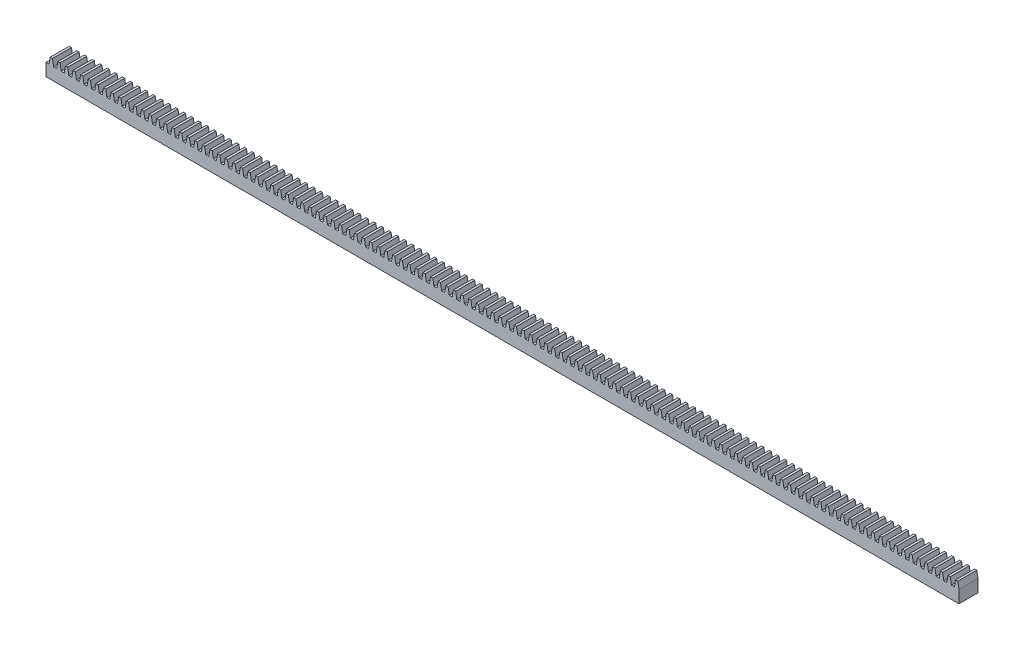
from build123d import *

# Parameters (mm, degrees)
SKETCH1_W           = 6.35
SKETCH1_H           = 6.35
BOSS_EXTRUDE1_DEPTH = 304.8
CUT_EXTRUDE1_DEPTH  = 304.8
SKETCH3_R           = 1.3462
CUT_EXTRUDE2_DEPTH  = 4.572


with BuildPart() as part:
    # Sketch1 → Boss-Extrude1 (new body)
    with BuildSketch(Plane(origin=(0, 0, 0), x_dir=(0, 0, -1), z_dir=(1, 0, 0))):
        with Locations((3.175, 3.175)):
            Rectangle(SKETCH1_W, SKETCH1_H)
    extrude(amount=-BOSS_EXTRUDE1_DEPTH)

    # Sketch2 → Cut-Extrude1 (cut)
    with BuildSketch(Plane.XY):
        Polygon((-5.08, 4.1402), (-5.469647362, 6.35), (-3.674352638, 6.35), (-4.064, 4.1402), align=None)
        Polygon((-1.524, 4.1402), (-1.134352638, 6.35), (-2.929647362, 6.35), (-2.54, 4.1402), align=None)
        Polygon((-7.62, 4.1402), (-8.009647362, 6.35), (-6.214352638, 6.35), (-6.604, 4.1402), align=None)
        Polygon((-10.16, 4.1402), (-10.549647362, 6.35), (-8.754352638, 6.35), (-9.144, 4.1402), align=None)
        Polygon((-12.7, 4.1402), (-13.089647362, 6.35), (-11.294352638, 6.35), (-11.684, 4.1402), align=None)
        Polygon((-15.24, 4.1402), (-15.629647362, 6.35), (-13.834352638, 6.35), (-14.224, 4.1402), align=None)
        Polygon((-17.78, 4.1402), (-18.169647362, 6.35), (-16.374352638, 6.35), (-16.764, 4.1402), align=None)
        Polygon((-20.32, 4.1402), (-20.709647362, 6.35), (-18.914352638, 6.35), (-19.304, 4.1402), align=None)
        Polygon((-22.86, 4.1402), (-23.249647362, 6.35), (-21.454352638, 6.35), (-21.844, 4.1402), align=None)
        Polygon((-25.4, 4.1402), (-25.789647362, 6.35), (-23.994352638, 6.35), (-24.384, 4.1402), align=None)
        Polygon((-27.94, 4.1402), (-28.329647362, 6.35), (-26.534352638, 6.35), (-26.924, 4.1402), align=None)
        Polygon((-30.48, 4.1402), (-30.869647362, 6.35), (-29.074352638, 6.35), (-29.464, 4.1402), align=None)
        Polygon((-33.02, 4.1402), (-33.409647362, 6.35), (-31.614352638, 6.35), (-32.004, 4.1402), align=None)
        Polygon((-35.56, 4.1402), (-35.949647362, 6.35), (-34.154352638, 6.35), (-34.544, 4.1402), align=None)
        Polygon((-38.1, 4.1402), (-38.489647362, 6.35), (-36.694352638, 6.35), (-37.084, 4.1402), align=None)
        Polygon((-40.64, 4.1402), (-41.029647362, 6.35), (-39.234352638, 6.35), (-39.624, 4.1402), align=None)
        Polygon((-43.18, 4.1402), (-43.569647362, 6.35), (-41.774352638, 6.35), (-42.164, 4.1402), align=None)
        Polygon((-45.72, 4.1402), (-46.109647362, 6.35), (-44.314352638, 6.35), (-44.704, 4.1402), align=None)
        Polygon((-48.26, 4.1402), (-48.649647362, 6.35), (-46.854352638, 6.35), (-47.244, 4.1402), align=None)
        Polygon((-50.8, 4.1402), (-51.189647362, 6.35), (-49.394352638, 6.35), (-49.784, 4.1402), align=None)
        Polygon((-53.34, 4.1402), (-53.729647362, 6.35), (-51.934352638, 6.35), (-52.324, 4.1402), align=None)
        Polygon((-55.88, 4.1402), (-56.269647362, 6.35), (-54.474352638, 6.35), (-54.864, 4.1402), align=None)
        Polygon((-58.42, 4.1402), (-58.809647362, 6.35), (-57.014352638, 6.35), (-57.404, 4.1402), align=None)
        Polygon((-60.96, 4.1402), (-61.349647362, 6.35), (-59.554352638, 6.35), (-59.944, 4.1402), align=None)
        Polygon((-63.5, 4.1402), (-63.889647362, 6.35), (-62.094352638, 6.35), (-62.484, 4.1402), align=None)
        Polygon((-66.04, 4.1402), (-66.429647362, 6.35), (-64.634352638, 6.35), (-65.024, 4.1402), align=None)
        Polygon((-68.58, 4.1402), (-68.969647362, 6.35), (-67.174352638, 6.35), (-67.564, 4.1402), align=None)
        Polygon((-71.12, 4.1402), (-71.509647362, 6.35), (-69.714352638, 6.35), (-70.104, 4.1402), align=None)
        Polygon((-73.66, 4.1402), (-74.049647362, 6.35), (-72.254352638, 6.35), (-72.644, 4.1402), align=None)
        Polygon((-76.2, 4.1402), (-76.589647362, 6.35), (-74.794352638, 6.35), (-75.184, 4.1402), align=None)
        Polygon((-78.74, 4.1402), (-79.129647362, 6.35), (-77.334352638, 6.35), (-77.724, 4.1402), align=None)
        Polygon((-81.28, 4.1402), (-81.669647362, 6.35), (-79.874352638, 6.35), (-80.264, 4.1402), align=None)
        Polygon((-83.82, 4.1402), (-84.209647362, 6.35), (-82.414352638, 6.35), (-82.804, 4.1402), align=None)
        Polygon((-86.36, 4.1402), (-86.749647362, 6.35), (-84.954352638, 6.35), (-85.344, 4.1402), align=None)
        Polygon((-88.9, 4.1402), (-89.289647362, 6.35), (-87.494352638, 6.35), (-87.884, 4.1402), align=None)
        Polygon((-91.44, 4.1402), (-91.829647362, 6.35), (-90.034352638, 6.35), (-90.424, 4.1402), align=None)
        Polygon((-93.98, 4.1402), (-94.369647362, 6.35), (-92.574352638, 6.35), (-92.964, 4.1402), align=None)
        Polygon((-96.52, 4.1402), (-96.909647362, 6.35), (-95.114352638, 6.35), (-95.504, 4.1402), align=None)
        Polygon((-99.06, 4.1402), (-99.449647362, 6.35), (-97.654352638, 6.35), (-98.044, 4.1402), align=None)
        Polygon((-101.6, 4.1402), (-101.989647362, 6.35), (-100.194352638, 6.35), (-100.584, 4.1402), align=None)
        Polygon((-104.14, 4.1402), (-104.529647362, 6.35), (-102.734352638, 6.35), (-103.124, 4.1402), align=None)
        Polygon((-106.68, 4.1402), (-107.069647362, 6.35), (-105.274352638, 6.35), (-105.664, 4.1402), align=None)
        Polygon((-109.22, 4.1402), (-109.609647362, 6.35), (-107.814352638, 6.35), (-108.204, 4.1402), align=None)
        Polygon((-111.76, 4.1402), (-112.149647362, 6.35), (-110.354352638, 6.35), (-110.744, 4.1402), align=None)
        Polygon((-114.3, 4.1402), (-114.689647362, 6.35), (-112.894352638, 6.35), (-113.284, 4.1402), align=None)
        Polygon((-116.84, 4.1402), (-117.229647362, 6.35), (-115.434352638, 6.35), (-115.824, 4.1402), align=None)
        Polygon((-119.38, 4.1402), (-119.769647362, 6.35), (-117.974352638, 6.35), (-118.364, 4.1402), align=None)
        Polygon((-121.92, 4.1402), (-122.309647362, 6.35), (-120.514352638, 6.35), (-120.904, 4.1402), align=None)
        Polygon((-124.46, 4.1402), (-124.849647362, 6.35), (-123.054352638, 6.35), (-123.444, 4.1402), align=None)
        Polygon((-127, 4.1402), (-127.389647362, 6.35), (-125.594352638, 6.35), (-125.984, 4.1402), align=None)
        Polygon((-129.54, 4.1402), (-129.929647362, 6.35), (-128.134352638, 6.35), (-128.524, 4.1402), align=None)
        Polygon((-132.08, 4.1402), (-132.469647362, 6.35), (-130.674352638, 6.35), (-131.064, 4.1402), align=None)
        Polygon((-134.62, 4.1402), (-135.009647362, 6.35), (-133.214352638, 6.35), (-133.604, 4.1402), align=None)
        Polygon((-137.16, 4.1402), (-137.549647362, 6.35), (-135.754352638, 6.35), (-136.144, 4.1402), align=None)
        Polygon((-139.7, 4.1402), (-140.089647362, 6.35), (-138.294352638, 6.35), (-138.684, 4.1402), align=None)
        Polygon((-142.24, 4.1402), (-142.629647362, 6.35), (-140.834352638, 6.35), (-141.224, 4.1402), align=None)
        Polygon((-144.78, 4.1402), (-145.169647362, 6.35), (-143.374352638, 6.35), (-143.764, 4.1402), align=None)
        Polygon((-147.32, 4.1402), (-147.709647362, 6.35), (-145.914352638, 6.35), (-146.304, 4.1402), align=None)
        Polygon((-149.86, 4.1402), (-150.249647362, 6.35), (-148.454352638, 6.35), (-148.844, 4.1402), align=None)
        Polygon((-152.4, 4.1402), (-152.789647362, 6.35), (-150.994352638, 6.35), (-151.384, 4.1402), align=None)
        Polygon((-154.94, 4.1402), (-155.329647362, 6.35), (-153.534352638, 6.35), (-153.924, 4.1402), align=None)
        Polygon((-157.48, 4.1402), (-157.869647362, 6.35), (-156.074352638, 6.35), (-156.464, 4.1402), align=None)
        Polygon((-160.02, 4.1402), (-160.409647362, 6.35), (-158.614352638, 6.35), (-159.004, 4.1402), align=None)
        Polygon((-162.56, 4.1402), (-162.949647362, 6.35), (-161.154352638, 6.35), (-161.544, 4.1402), align=None)
        Polygon((-165.1, 4.1402), (-165.489647362, 6.35), (-163.694352638, 6.35), (-164.084, 4.1402), align=None)
        Polygon((-167.64, 4.1402), (-168.029647362, 6.35), (-166.234352638, 6.35), (-166.624, 4.1402), align=None)
        Polygon((-170.18, 4.1402), (-170.569647362, 6.35), (-168.774352638, 6.35), (-169.164, 4.1402), align=None)
        Polygon((-172.72, 4.1402), (-173.109647362, 6.35), (-171.314352638, 6.35), (-171.704, 4.1402), align=None)
        Polygon((-175.26, 4.1402), (-175.649647362, 6.35), (-173.854352638, 6.35), (-174.244, 4.1402), align=None)
        Polygon((-177.8, 4.1402), (-178.189647362, 6.35), (-176.394352638, 6.35), (-176.784, 4.1402), align=None)
        Polygon((-180.34, 4.1402), (-180.729647362, 6.35), (-178.934352638, 6.35), (-179.324, 4.1402), align=None)
        Polygon((-182.88, 4.1402), (-183.269647362, 6.35), (-181.474352638, 6.35), (-181.864, 4.1402), align=None)
        Polygon((-185.42, 4.1402), (-185.809647362, 6.35), (-184.014352638, 6.35), (-184.404, 4.1402), align=None)
        Polygon((-187.96, 4.1402), (-188.349647362, 6.35), (-186.554352638, 6.35), (-186.944, 4.1402), align=None)
        Polygon((-190.5, 4.1402), (-190.889647362, 6.35), (-189.094352638, 6.35), (-189.484, 4.1402), align=None)
        Polygon((-193.04, 4.1402), (-193.429647362, 6.35), (-191.634352638, 6.35), (-192.024, 4.1402), align=None)
        Polygon((-195.58, 4.1402), (-195.969647362, 6.35), (-194.174352638, 6.35), (-194.564, 4.1402), align=None)
        Polygon((-198.12, 4.1402), (-198.509647362, 6.35), (-196.714352638, 6.35), (-197.104, 4.1402), align=None)
        Polygon((-200.66, 4.1402), (-201.049647362, 6.35), (-199.254352638, 6.35), (-199.644, 4.1402), align=None)
        Polygon((-203.2, 4.1402), (-203.589647362, 6.35), (-201.794352638, 6.35), (-202.184, 4.1402), align=None)
        Polygon((-205.74, 4.1402), (-206.129647362, 6.35), (-204.334352638, 6.35), (-204.724, 4.1402), align=None)
        Polygon((-208.28, 4.1402), (-208.669647362, 6.35), (-206.874352638, 6.35), (-207.264, 4.1402), align=None)
        Polygon((-210.82, 4.1402), (-211.209647362, 6.35), (-209.414352638, 6.35), (-209.804, 4.1402), align=None)
        Polygon((-213.36, 4.1402), (-213.749647362, 6.35), (-211.954352638, 6.35), (-212.344, 4.1402), align=None)
        Polygon((-215.9, 4.1402), (-216.289647362, 6.35), (-214.494352638, 6.35), (-214.884, 4.1402), align=None)
        Polygon((-218.44, 4.1402), (-218.829647362, 6.35), (-217.034352638, 6.35), (-217.424, 4.1402), align=None)
        Polygon((-220.98, 4.1402), (-221.369647362, 6.35), (-219.574352638, 6.35), (-219.964, 4.1402), align=None)
        Polygon((-223.52, 4.1402), (-223.909647362, 6.35), (-222.114352638, 6.35), (-222.504, 4.1402), align=None)
        Polygon((-226.06, 4.1402), (-226.449647362, 6.35), (-224.654352638, 6.35), (-225.044, 4.1402), align=None)
        Polygon((-228.6, 4.1402), (-228.989647362, 6.35), (-227.194352638, 6.35), (-227.584, 4.1402), align=None)
        Polygon((-231.14, 4.1402), (-231.529647362, 6.35), (-229.734352638, 6.35), (-230.124, 4.1402), align=None)
        Polygon((-233.68, 4.1402), (-234.069647362, 6.35), (-232.274352638, 6.35), (-232.664, 4.1402), align=None)
        Polygon((-236.22, 4.1402), (-236.609647362, 6.35), (-234.814352638, 6.35), (-235.204, 4.1402), align=None)
        Polygon((-238.76, 4.1402), (-239.149647362, 6.35), (-237.354352638, 6.35), (-237.744, 4.1402), align=None)
        Polygon((-241.3, 4.1402), (-241.689647362, 6.35), (-239.894352638, 6.35), (-240.284, 4.1402), align=None)
        Polygon((-243.84, 4.1402), (-244.229647362, 6.35), (-242.434352638, 6.35), (-242.824, 4.1402), align=None)
        Polygon((-246.38, 4.1402), (-246.769647362, 6.35), (-244.974352638, 6.35), (-245.364, 4.1402), align=None)
        Polygon((-248.92, 4.1402), (-249.309647362, 6.35), (-247.514352638, 6.35), (-247.904, 4.1402), align=None)
        Polygon((-251.46, 4.1402), (-251.849647362, 6.35), (-250.054352638, 6.35), (-250.444, 4.1402), align=None)
        Polygon((-254, 4.1402), (-254.389647362, 6.35), (-252.594352638, 6.35), (-252.984, 4.1402), align=None)
        Polygon((-256.54, 4.1402), (-256.929647362, 6.35), (-255.134352638, 6.35), (-255.524, 4.1402), align=None)
        Polygon((-259.08, 4.1402), (-259.469647362, 6.35), (-257.674352638, 6.35), (-258.064, 4.1402), align=None)
        Polygon((-261.62, 4.1402), (-262.009647362, 6.35), (-260.214352638, 6.35), (-260.604, 4.1402), align=None)
        Polygon((-264.16, 4.1402), (-264.549647362, 6.35), (-262.754352638, 6.35), (-263.144, 4.1402), align=None)
        Polygon((-266.7, 4.1402), (-267.089647362, 6.35), (-265.294352638, 6.35), (-265.684, 4.1402), align=None)
        Polygon((-269.24, 4.1402), (-269.629647362, 6.35), (-267.834352638, 6.35), (-268.224, 4.1402), align=None)
        Polygon((-271.78, 4.1402), (-272.169647362, 6.35), (-270.374352638, 6.35), (-270.764, 4.1402), align=None)
        Polygon((-274.32, 4.1402), (-274.709647362, 6.35), (-272.914352638, 6.35), (-273.304, 4.1402), align=None)
        Polygon((-276.86, 4.1402), (-277.249647362, 6.35), (-275.454352638, 6.35), (-275.844, 4.1402), align=None)
        Polygon((-279.4, 4.1402), (-279.789647362, 6.35), (-277.994352638, 6.35), (-278.384, 4.1402), align=None)
        Polygon((-281.94, 4.1402), (-282.329647362, 6.35), (-280.534352638, 6.35), (-280.924, 4.1402), align=None)
        Polygon((-284.48, 4.1402), (-284.869647362, 6.35), (-283.074352638, 6.35), (-283.464, 4.1402), align=None)
        Polygon((-287.02, 4.1402), (-287.409647362, 6.35), (-285.614352638, 6.35), (-286.004, 4.1402), align=None)
        Polygon((-289.56, 4.1402), (-289.949647362, 6.35), (-288.154352638, 6.35), (-288.544, 4.1402), align=None)
        Polygon((-292.1, 4.1402), (-292.489647362, 6.35), (-290.694352638, 6.35), (-291.084, 4.1402), align=None)
        Polygon((-294.64, 4.1402), (-295.029647362, 6.35), (-293.234352638, 6.35), (-293.624, 4.1402), align=None)
        Polygon((-297.18, 4.1402), (-297.569647362, 6.35), (-295.774352638, 6.35), (-296.164, 4.1402), align=None)
        Polygon((-299.72, 4.1402), (-300.109647362, 6.35), (-298.314352638, 6.35), (-298.704, 4.1402), align=None)
        Polygon((-302.26, 4.1402), (-302.649647362, 6.35), (-300.854352638, 6.35), (-301.244, 4.1402), align=None)
        Polygon((-304.8, 4.1402), (-305.189647362, 6.35), (-303.394352638, 6.35), (-303.784, 4.1402), align=None)
        Polygon((-0.397752638, 6.35), (0, 6.35), (0, 4.1402), align=None)
    extrude(amount=-CUT_EXTRUDE1_DEPTH, mode=Mode.SUBTRACT)

    # Sketch3 → Cut-Extrude2 (cut)
    with BuildSketch(Plane.XZ):
        with Locations((-19.05, -3.175)):
            Circle(SKETCH3_R)
        with Locations((-152.4, -3.175)):
            Circle(SKETCH3_R)
        with Locations((-285.75, -3.175)):
            Circle(SKETCH3_R)
    extrude(amount=-CUT_EXTRUDE2_DEPTH, mode=Mode.SUBTRACT)


solid = part.part
